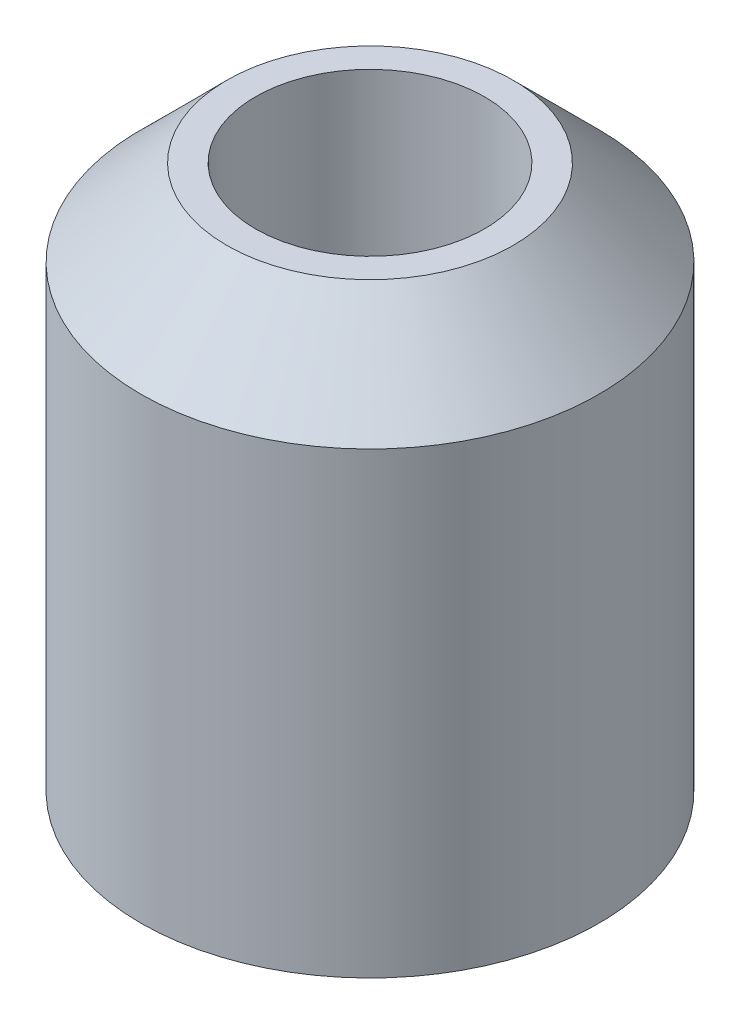
from build123d import *


with BuildPart() as part:
    # Skizze1 → Rotation1 (revolve)
    with BuildSketch(Plane.XY):
        Polygon((-2, 9.5), (-2.5, 9.5), (-4, 8), (-4, 0), (-2, 0), align=None)
    revolve(axis=Axis((0, 27.213035184, 0), (0, -1, 0)))


solid = part.part
